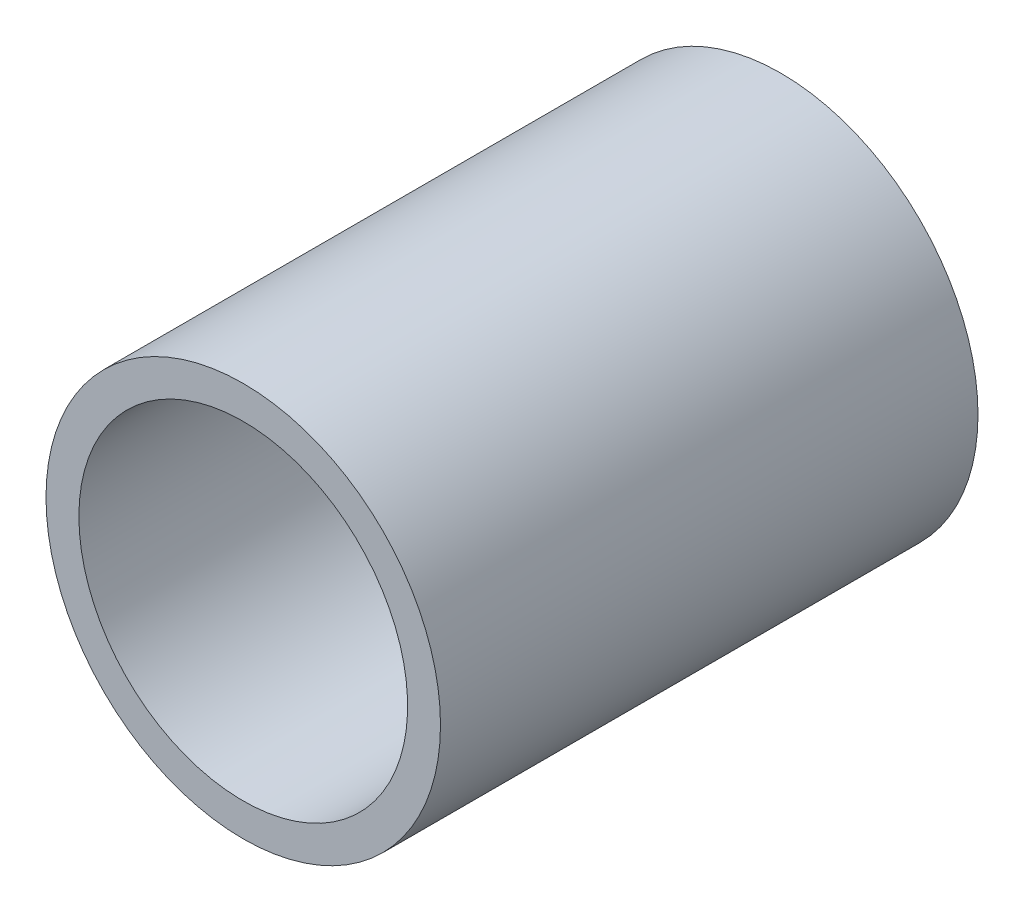
from build123d import *

# Parameters (mm, degrees)
SKETCH1_R           = 6
SKETCH1_R_2         = 5
BOSS_EXTRUDE1_DEPTH = 16.35


with BuildPart() as part:
    # Sketch1 → Boss-Extrude1 (new body)
    with BuildSketch(Plane.XY):
        Circle(SKETCH1_R)
        Circle(SKETCH1_R_2, mode=Mode.SUBTRACT)
    extrude(amount=BOSS_EXTRUDE1_DEPTH)


solid = part.part
